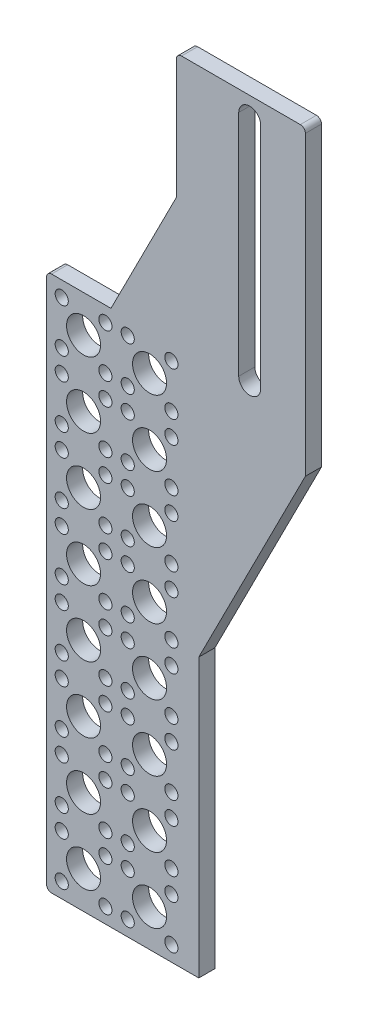
from build123d import *

# Parameters (mm, degrees)
SKETCH2_R           = 1.2954
SKETCH2_R_2         = 3.35
BOSS_EXTRUDE1_DEPTH = 3.175
FILLET1_R           = 1
FILLET2_R           = 1


with BuildPart() as part:
    # Sketch2 → Boss-Extrude1 (new body)
    with BuildSketch(Plane.XY):
        Polygon((-115.54, -30.131), (-128.24, -30.131), (-128.24, -135.731), (-98.24, -135.731), (-98.24, -80.979837209), (-77.24, -39.631), (-77.24, 19.869), (-102.64, 19.869), (-102.64, -4.731), align=None)
        with BuildLine():
            Line((-90.372732921, -29.131), (-90.372732921, 15.869))
            ThreePointArc((-90.372732921, 15.869), (-88.212732921, 18.029), (-86.052732921, 15.869))
            Line((-86.052732921, 15.869), (-86.052732921, -29.131))
            ThreePointArc((-86.052732921, -29.131), (-88.212732921, -31.291), (-90.372732921, -29.131))
        make_face(mode=Mode.SUBTRACT)
        with Locations((-125.24, -132.731)):
            Circle(SKETCH2_R, mode=Mode.SUBTRACT)
        with Locations((-125.24, -124.131)):
            Circle(SKETCH2_R, mode=Mode.SUBTRACT)
        with Locations((-125.24, -119.731)):
            Circle(SKETCH2_R, mode=Mode.SUBTRACT)
        with Locations((-120.94, -128.431)):
            Circle(SKETCH2_R_2, mode=Mode.SUBTRACT)
        with Locations((-116.64, -132.731)):
            Circle(SKETCH2_R, mode=Mode.SUBTRACT)
        with Locations((-116.64, -124.131)):
            Circle(SKETCH2_R, mode=Mode.SUBTRACT)
        with Locations((-116.64, -119.731)):
            Circle(SKETCH2_R, mode=Mode.SUBTRACT)
        with Locations((-125.24, -111.131)):
            Circle(SKETCH2_R, mode=Mode.SUBTRACT)
        with Locations((-125.24, -106.731)):
            Circle(SKETCH2_R, mode=Mode.SUBTRACT)
        with Locations((-125.24, -98.131)):
            Circle(SKETCH2_R, mode=Mode.SUBTRACT)
        with Locations((-120.94, -115.431)):
            Circle(SKETCH2_R_2, mode=Mode.SUBTRACT)
        with Locations((-116.64, -111.131)):
            Circle(SKETCH2_R, mode=Mode.SUBTRACT)
        with Locations((-116.64, -106.731)):
            Circle(SKETCH2_R, mode=Mode.SUBTRACT)
        with Locations((-120.94, -102.431)):
            Circle(SKETCH2_R_2, mode=Mode.SUBTRACT)
        with Locations((-116.64, -98.131)):
            Circle(SKETCH2_R, mode=Mode.SUBTRACT)
        with Locations((-112.24, -132.731)):
            Circle(SKETCH2_R, mode=Mode.SUBTRACT)
        with Locations((-112.24, -124.131)):
            Circle(SKETCH2_R, mode=Mode.SUBTRACT)
        with Locations((-112.24, -119.731)):
            Circle(SKETCH2_R, mode=Mode.SUBTRACT)
        with Locations((-107.94, -128.431)):
            Circle(SKETCH2_R_2, mode=Mode.SUBTRACT)
        with Locations((-103.64, -132.731)):
            Circle(SKETCH2_R, mode=Mode.SUBTRACT)
        with Locations((-103.64, -124.131)):
            Circle(SKETCH2_R, mode=Mode.SUBTRACT)
        with Locations((-103.64, -119.731)):
            Circle(SKETCH2_R, mode=Mode.SUBTRACT)
        with Locations((-112.24, -111.131)):
            Circle(SKETCH2_R, mode=Mode.SUBTRACT)
        with Locations((-112.24, -106.731)):
            Circle(SKETCH2_R, mode=Mode.SUBTRACT)
        with Locations((-112.24, -98.131)):
            Circle(SKETCH2_R, mode=Mode.SUBTRACT)
        with Locations((-107.94, -115.431)):
            Circle(SKETCH2_R_2, mode=Mode.SUBTRACT)
        with Locations((-103.64, -111.131)):
            Circle(SKETCH2_R, mode=Mode.SUBTRACT)
        with Locations((-103.64, -106.731)):
            Circle(SKETCH2_R, mode=Mode.SUBTRACT)
        with Locations((-107.94, -102.431)):
            Circle(SKETCH2_R_2, mode=Mode.SUBTRACT)
        with Locations((-103.64, -98.131)):
            Circle(SKETCH2_R, mode=Mode.SUBTRACT)
        with Locations((-125.24, -93.731)):
            Circle(SKETCH2_R, mode=Mode.SUBTRACT)
        with Locations((-125.24, -85.131)):
            Circle(SKETCH2_R, mode=Mode.SUBTRACT)
        with Locations((-125.24, -80.731)):
            Circle(SKETCH2_R, mode=Mode.SUBTRACT)
        with Locations((-120.94, -89.431)):
            Circle(SKETCH2_R_2, mode=Mode.SUBTRACT)
        with Locations((-116.64, -93.731)):
            Circle(SKETCH2_R, mode=Mode.SUBTRACT)
        with Locations((-116.64, -85.131)):
            Circle(SKETCH2_R, mode=Mode.SUBTRACT)
        with Locations((-116.64, -80.731)):
            Circle(SKETCH2_R, mode=Mode.SUBTRACT)
        with Locations((-125.24, -72.131)):
            Circle(SKETCH2_R, mode=Mode.SUBTRACT)
        with Locations((-125.24, -67.731)):
            Circle(SKETCH2_R, mode=Mode.SUBTRACT)
        with Locations((-125.24, -59.131)):
            Circle(SKETCH2_R, mode=Mode.SUBTRACT)
        with Locations((-120.94, -76.431)):
            Circle(SKETCH2_R_2, mode=Mode.SUBTRACT)
        with Locations((-116.64, -72.131)):
            Circle(SKETCH2_R, mode=Mode.SUBTRACT)
        with Locations((-116.64, -67.731)):
            Circle(SKETCH2_R, mode=Mode.SUBTRACT)
        with Locations((-120.94, -63.431)):
            Circle(SKETCH2_R_2, mode=Mode.SUBTRACT)
        with Locations((-116.64, -59.131)):
            Circle(SKETCH2_R, mode=Mode.SUBTRACT)
        with Locations((-112.24, -93.731)):
            Circle(SKETCH2_R, mode=Mode.SUBTRACT)
        with Locations((-112.24, -85.131)):
            Circle(SKETCH2_R, mode=Mode.SUBTRACT)
        with Locations((-112.24, -80.731)):
            Circle(SKETCH2_R, mode=Mode.SUBTRACT)
        with Locations((-107.94, -89.431)):
            Circle(SKETCH2_R_2, mode=Mode.SUBTRACT)
        with Locations((-103.64, -93.731)):
            Circle(SKETCH2_R, mode=Mode.SUBTRACT)
        with Locations((-103.64, -85.131)):
            Circle(SKETCH2_R, mode=Mode.SUBTRACT)
        with Locations((-103.64, -80.731)):
            Circle(SKETCH2_R, mode=Mode.SUBTRACT)
        with Locations((-112.24, -72.131)):
            Circle(SKETCH2_R, mode=Mode.SUBTRACT)
        with Locations((-112.24, -67.731)):
            Circle(SKETCH2_R, mode=Mode.SUBTRACT)
        with Locations((-112.24, -59.131)):
            Circle(SKETCH2_R, mode=Mode.SUBTRACT)
        with Locations((-107.94, -76.431)):
            Circle(SKETCH2_R_2, mode=Mode.SUBTRACT)
        with Locations((-103.64, -72.131)):
            Circle(SKETCH2_R, mode=Mode.SUBTRACT)
        with Locations((-103.64, -67.731)):
            Circle(SKETCH2_R, mode=Mode.SUBTRACT)
        with Locations((-107.94, -63.431)):
            Circle(SKETCH2_R_2, mode=Mode.SUBTRACT)
        with Locations((-103.64, -59.131)):
            Circle(SKETCH2_R, mode=Mode.SUBTRACT)
        with Locations((-125.24, -54.731)):
            Circle(SKETCH2_R, mode=Mode.SUBTRACT)
        with Locations((-125.24, -46.131)):
            Circle(SKETCH2_R, mode=Mode.SUBTRACT)
        with Locations((-125.24, -41.731)):
            Circle(SKETCH2_R, mode=Mode.SUBTRACT)
        with Locations((-120.94, -50.431)):
            Circle(SKETCH2_R_2, mode=Mode.SUBTRACT)
        with Locations((-116.64, -54.731)):
            Circle(SKETCH2_R, mode=Mode.SUBTRACT)
        with Locations((-116.64, -46.131)):
            Circle(SKETCH2_R, mode=Mode.SUBTRACT)
        with Locations((-116.64, -41.731)):
            Circle(SKETCH2_R, mode=Mode.SUBTRACT)
        with Locations((-125.24, -33.131)):
            Circle(SKETCH2_R, mode=Mode.SUBTRACT)
        with Locations((-120.94, -37.431)):
            Circle(SKETCH2_R_2, mode=Mode.SUBTRACT)
        with Locations((-116.64, -33.131)):
            Circle(SKETCH2_R, mode=Mode.SUBTRACT)
        with Locations((-112.24, -54.731)):
            Circle(SKETCH2_R, mode=Mode.SUBTRACT)
        with Locations((-112.24, -46.131)):
            Circle(SKETCH2_R, mode=Mode.SUBTRACT)
        with Locations((-112.24, -41.731)):
            Circle(SKETCH2_R, mode=Mode.SUBTRACT)
        with Locations((-107.94, -50.431)):
            Circle(SKETCH2_R_2, mode=Mode.SUBTRACT)
        with Locations((-103.64, -54.731)):
            Circle(SKETCH2_R, mode=Mode.SUBTRACT)
        with Locations((-103.64, -46.131)):
            Circle(SKETCH2_R, mode=Mode.SUBTRACT)
        with Locations((-103.64, -41.731)):
            Circle(SKETCH2_R, mode=Mode.SUBTRACT)
        with Locations((-112.24, -33.131)):
            Circle(SKETCH2_R, mode=Mode.SUBTRACT)
        with Locations((-107.94, -37.431)):
            Circle(SKETCH2_R_2, mode=Mode.SUBTRACT)
        with Locations((-103.64, -33.131)):
            Circle(SKETCH2_R, mode=Mode.SUBTRACT)
    extrude(amount=BOSS_EXTRUDE1_DEPTH)

    # Fillet1
    fillet1_edges = [part.edges().sort_by_distance(p)[0] for p in [
        (-102.64, 19.869, 1.5875),
    ]]
    fillet(fillet1_edges, radius=FILLET1_R)

    # Fillet2
    fillet2_edges = [part.edges().sort_by_distance(p)[0] for p in [
        (-128.24, -135.731, 1.5875),
        (-128.24, -30.131, 1.5875),
        (-77.24, 19.869, 1.5875),
    ]]
    fillet(fillet2_edges, radius=FILLET2_R)


solid = part.part
